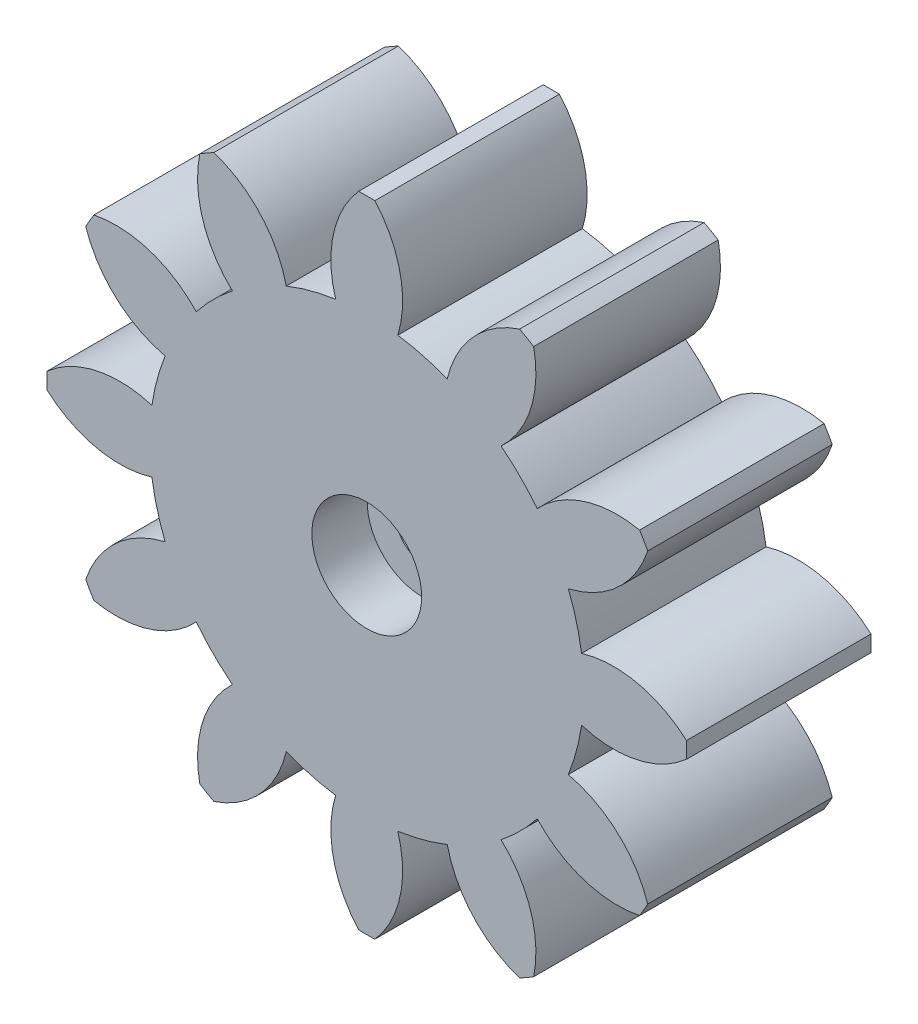
from build123d import *

# Parameters (mm, degrees)
BOSS_EXTRUDE1_DEPTH = 10
SKETCH3_R           = 2.975
CUT_EXTRUDE1_DEPTH  = 3
SKETCH4_R           = 2.975
CUT_EXTRUDE2_DEPTH  = 5
CUT_EXTRUDE3_REACH  = 7
SKETCH5_R           = 1.375
CUT_EXTRUDE4_DEPTH  = 0.4


with BuildPart() as part:
    # Sketch1 → Boss-Extrude1 (new body)
    with BuildSketch(Plane.XY):
        with BuildLine():
            ThreePointArc((10.92443124, -4.361437941), (11.362069294, -3.044457292), (11.641553947, -1.685099566))
            ThreePointArc((11.641553947, -1.685099566), (14.648632583, -1.806960077), (17.329910897, -0.440168758))
            ThreePointArc((17.329910897, -0.440168758), (17.3355, 0), (17.329910897, 0.440168758))
            ThreePointArc((17.329910897, 0.440168758), (14.648632583, 1.806960077), (11.641553947, 1.685099566))
            ThreePointArc((11.641553947, 1.685099566), (11.362069294, 3.044457292), (10.92443124, 4.361437941))
            ThreePointArc((10.92443124, 4.361437941), (13.589567986, 5.759442961), (15.228227462, 8.283758122))
            ThreePointArc((15.228227462, 8.283758122), (15.012983387, 8.66775), (14.788058703, 9.046152775))
            ThreePointArc((14.788058703, 9.046152775), (11.782607909, 8.889189622), (9.239331674, 7.280116005))
            ThreePointArc((9.239331674, 7.280116005), (8.317612002, 8.317612002), (7.280116005, 9.239331674))
            ThreePointArc((7.280116005, 9.239331674), (8.889189622, 11.782607909), (9.046152775, 14.788058703))
            ThreePointArc((9.046152775, 14.788058703), (8.66775, 15.012983387), (8.283758122, 15.228227462))
            ThreePointArc((8.283758122, 15.228227462), (5.759442961, 13.589567986), (4.361437941, 10.92443124))
            ThreePointArc((4.361437941, 10.92443124), (3.044457292, 11.362069294), (1.685099566, 11.641553947))
            ThreePointArc((1.685099566, 11.641553947), (1.806960077, 14.648632583), (0.440168758, 17.329910897))
            ThreePointArc((0.440168758, 17.329910897), (0, 17.3355), (-0.440168758, 17.329910897))
            ThreePointArc((-0.440168758, 17.329910897), (-1.806960077, 14.648632583), (-1.685099566, 11.641553947))
            ThreePointArc((-1.685099566, 11.641553947), (-3.044457292, 11.362069294), (-4.361437941, 10.92443124))
            ThreePointArc((-4.361437941, 10.92443124), (-5.759442961, 13.589567986), (-8.283758122, 15.228227462))
            ThreePointArc((-8.283758122, 15.228227462), (-8.66775, 15.012983387), (-9.046152775, 14.788058703))
            ThreePointArc((-9.046152775, 14.788058703), (-8.889189622, 11.782607909), (-7.280116005, 9.239331674))
            ThreePointArc((-7.280116005, 9.239331674), (-8.317612002, 8.317612002), (-9.239331674, 7.280116005))
            ThreePointArc((-9.239331674, 7.280116005), (-11.782607909, 8.889189622), (-14.788058703, 9.046152775))
            ThreePointArc((-14.788058703, 9.046152775), (-15.012983387, 8.66775), (-15.228227462, 8.283758122))
            ThreePointArc((-15.228227462, 8.283758122), (-13.589567986, 5.759442961), (-10.92443124, 4.361437941))
            ThreePointArc((-10.92443124, 4.361437941), (-11.362069294, 3.044457292), (-11.641553947, 1.685099566))
            ThreePointArc((-11.641553947, 1.685099566), (-14.648632583, 1.806960077), (-17.329910897, 0.440168758))
            ThreePointArc((-17.329910897, 0.440168758), (-17.3355, 0), (-17.329910897, -0.440168758))
            ThreePointArc((-17.329910897, -0.440168758), (-14.648632583, -1.806960077), (-11.641553947, -1.685099566))
            ThreePointArc((-11.641553947, -1.685099566), (-11.362069294, -3.044457292), (-10.92443124, -4.361437941))
            ThreePointArc((-10.92443124, -4.361437941), (-13.589567986, -5.759442961), (-15.228227462, -8.283758122))
            ThreePointArc((-15.228227462, -8.283758122), (-15.012983387, -8.66775), (-14.788058703, -9.046152775))
            ThreePointArc((-14.788058703, -9.046152775), (-11.782607909, -8.889189622), (-9.239331674, -7.280116005))
            ThreePointArc((-9.239331674, -7.280116005), (-8.317612002, -8.317612002), (-7.280116005, -9.239331674))
            ThreePointArc((-7.280116005, -9.239331674), (-8.889189622, -11.782607909), (-9.046152775, -14.788058703))
            ThreePointArc((-9.046152775, -14.788058703), (-8.66775, -15.012983387), (-8.283758122, -15.228227462))
            ThreePointArc((-8.283758122, -15.228227462), (-5.759442961, -13.589567986), (-4.361437941, -10.92443124))
            ThreePointArc((-4.361437941, -10.92443124), (-3.044457292, -11.362069294), (-1.685099566, -11.641553947))
            ThreePointArc((-1.685099566, -11.641553947), (-1.806960077, -14.648632583), (-0.440168758, -17.329910897))
            ThreePointArc((-0.440168758, -17.329910897), (0, -17.3355), (0.440168758, -17.329910897))
            ThreePointArc((0.440168758, -17.329910897), (1.806960077, -14.648632583), (1.685099566, -11.641553947))
            ThreePointArc((1.685099566, -11.641553947), (3.044457292, -11.362069294), (4.361437941, -10.92443124))
            ThreePointArc((4.361437941, -10.92443124), (5.759442961, -13.589567986), (8.283758122, -15.228227462))
            ThreePointArc((8.283758122, -15.228227462), (8.66775, -15.012983387), (9.046152775, -14.788058703))
            ThreePointArc((9.046152775, -14.788058703), (8.889189622, -11.782607909), (7.280116005, -9.239331674))
            ThreePointArc((7.280116005, -9.239331674), (8.317612002, -8.317612002), (9.239331674, -7.280116005))
            ThreePointArc((9.239331674, -7.280116005), (11.782607909, -8.889189622), (14.788058703, -9.046152775))
            ThreePointArc((14.788058703, -9.046152775), (15.012983387, -8.66775), (15.228227462, -8.283758122))
            ThreePointArc((15.228227462, -8.283758122), (13.589567986, -5.759442961), (10.92443124, -4.361437941))
        make_face()
    extrude(amount=BOSS_EXTRUDE1_DEPTH)

    # Sketch3 → Cut-Extrude1 (cut)
    with BuildSketch(Plane.XY.offset(10)):
        Circle(SKETCH3_R)
    extrude(amount=-CUT_EXTRUDE1_DEPTH, mode=Mode.SUBTRACT)

    # Sketch4 → Cut-Extrude2 (cut)
    with BuildSketch(Plane(origin=(0, 0, 0), x_dir=(-1, 0, 0), z_dir=(0, 0, -1))):
        Circle(SKETCH4_R)
    extrude(amount=-CUT_EXTRUDE2_DEPTH, mode=Mode.SUBTRACT)

    # Sketch5 → Cut-Extrude3 (cut, up to next)
    with BuildSketch(Plane(origin=(0, 0, 5), x_dir=(-1, 0, 0), z_dir=(0, 0, -1)), mode=Mode.PRIVATE) as cut_extrude3_sk1:
        Circle(SKETCH5_R)
    cut_extrude3_tool1 = extrude(cut_extrude3_sk1.sketch, amount=-CUT_EXTRUDE3_REACH, mode=Mode.PRIVATE) & part.part
    add(cut_extrude3_tool1.solids().sort_by_distance((0, 0, 5))[0], mode=Mode.SUBTRACT)

    # Sketch6 → Cut-Extrude4 (cut)
    with BuildSketch(Plane(origin=(0, 0, 0), x_dir=(-1, 0, 0), z_dir=(0, 0, -1))):
        Polygon((-2.618216479, 7.598722954), (-1.369925881, 7.598722954), (-1.397062633, 7.408765689), (-1.914356971, 7.408765689), (-2.18275641, 5.482056288), (-2.37398571, 5.482056288), (-2.105586271, 7.408765689), (-2.645353231, 7.408765689), align=None)
        with BuildLine():
            add(Edge.make_bspline(
                [(-0.466780849, 7.055987912), (-0.450230711, 7.05582637), (-0.417344464, 7.055505377), (-0.368540996, 7.050389965), (-0.320631892, 7.043455272), (-0.273890681, 7.033209653), (-0.228274333, 7.020039405), (-0.183797047, 7.003718771), (-0.139886963, 6.985373988), (-0.097861943, 6.963061744), (-0.056959643, 6.93914658), (-0.018469172, 6.912248414), (0.018217553, 6.883553528), (0.05209848, 6.852068656), (0.083565028, 6.818384713), (0.113001423, 6.782640371), (0.140098105, 6.744546559), (0.164595462, 6.704227452), (0.186767697, 6.662267959), (0.205810076, 6.618582201), (0.221812473, 6.573454595), (0.235635063, 6.527284032), (0.245748638, 6.479469202), (0.252716265, 6.430299353), (0.25780439, 6.379794636), (0.25811986, 6.345639936), (0.258279247, 6.328383745)],
                knots=[0, 0, 0, 0, 4.9626e-05, 9.861e-05, 0.000147062, 0.000194801, 0.000242036, 0.000289383, 0.000336874, 0.000384665, 0.000432005, 0.000478934, 0.000525421, 0.000571629, 0.000617526, 0.000663618, 0.000710444, 0.000757639, 0.000805055, 0.000852714, 0.00090046, 0.000948628, 0.000997195, 0.001046906, 0.001097579, 0.001149324, 0.001149324, 0.001149324, 0.001149324], degree=3))
            add(Edge.make_bspline(
                [(0.258279247, 6.328383745), (0.258039783, 6.308578593), (0.257564863, 6.269299702), (0.25111703, 6.210994824), (0.242013556, 6.153590639), (0.228820877, 6.097203636), (0.211893663, 6.041919503), (0.190810327, 5.98797899), (0.166897365, 5.934727262), (0.138391513, 5.883395436), (0.107072302, 5.833870752), (0.073382761, 5.786755537), (0.036549617, 5.742935538), (-0.002372315, 5.701702817), (-0.04403848, 5.66345401), (-0.088426282, 5.628104243), (-0.135229578, 5.595522836), (-0.184676123, 5.566327033), (-0.235762168, 5.539867628), (-0.289219479, 5.517520108), (-0.344037548, 5.497877287), (-0.400776526, 5.482306102), (-0.458924002, 5.469780542), (-0.519048579, 5.461676665), (-0.580721407, 5.455726724), (-0.622519609, 5.455190096), (-0.643593749, 5.454919536)],
                knots=[0, 0, 0, 0, 5.9386e-05, 0.000117778, 0.000175775, 0.00023368, 0.000291352, 0.00034907, 0.000407322, 0.000466339, 0.000525038, 0.000583054, 0.000639949, 0.000696635, 0.000753052, 0.000809471, 0.000866752, 0.000923981, 0.00098163, 0.001039198, 0.001097669, 0.001156204, 0.001215581, 0.001275965, 0.001338116, 0.001401316, 0.001401316, 0.001401316, 0.001401316], degree=3))
            add(Edge.make_bspline(
                [(-0.643593749, 5.454919536), (-0.669493428, 5.455383045), (-0.720215087, 5.456290778), (-0.79439634, 5.466548474), (-0.865066012, 5.482132761), (-0.932596844, 5.503609688), (-0.996247222, 5.532258194), (-1.056572504, 5.566773789), (-1.113195168, 5.607790827), (-1.165981922, 5.654584393), (-1.213474215, 5.70648827), (-1.255599117, 5.761915733), (-1.290839566, 5.821150442), (-1.31984552, 5.88380972), (-1.342346636, 5.949908511), (-1.358542659, 6.019333173), (-1.367836177, 6.092239873), (-1.369220429, 6.141933883), (-1.369925881, 6.167259279)],
                knots=[0, 0, 0, 0, 7.7651e-05, 0.000152071, 0.000224184, 0.000294581, 0.000364239, 0.000433188, 0.000502737, 0.00057362, 0.000644441, 0.00071347, 0.000782116, 0.000850791, 0.000920249, 0.000991216, 0.00106432, 0.001140294, 0.001140294, 0.001140294, 0.001140294], degree=3))
            add(Edge.make_bspline(
                [(-1.369925881, 6.167259279), (-1.369686634, 6.187346849), (-1.369212104, 6.227189251), (-1.362759891, 6.286341002), (-1.353696191, 6.344455032), (-1.340515163, 6.40142391), (-1.323365754, 6.45698532), (-1.303239948, 6.51160935), (-1.278207847, 6.564567741), (-1.250581409, 6.616609619), (-1.219162465, 6.666555184), (-1.184856791, 6.713974777), (-1.147928001, 6.75876754), (-1.107808488, 6.800408128), (-1.065080124, 6.839424555), (-1.019448587, 6.875464179), (-0.9715212, 6.909223719), (-0.920623878, 6.939512396), (-0.868016329, 6.966960034), (-0.813961342, 6.990907617), (-0.758740152, 7.010651127), (-0.702629226, 7.02747186), (-0.645186655, 7.040029408), (-0.586743519, 7.049425439), (-0.527104511, 7.055120684), (-0.487004359, 7.055697173), (-0.466780849, 7.055987912)],
                knots=[0, 0, 0, 0, 6.0234e-05, 0.000119469, 0.000178303, 0.000236621, 0.000294699, 0.000352663, 0.000411092, 0.000470279, 0.000529337, 0.000587944, 0.000645762, 0.000703341, 0.000761269, 0.000819212, 0.000877673, 0.00093701, 0.000996749, 0.001055602, 0.001114215, 0.001172576, 0.001231214, 0.001290467, 0.001350084, 0.001410741, 0.001410741, 0.001410741, 0.001410741], degree=3))
        make_face()
        with BuildLine():
            add(Edge.make_bspline(
                [(-0.472293002, 6.866030647), (-0.503747094, 6.865022695), (-0.566133209, 6.863023522), (-0.658065178, 6.845395471), (-0.74697014, 6.81671419), (-0.8179001, 6.783908088), (-0.872314578, 6.752977498), (-0.910614571, 6.727193913), (-0.946742967, 6.69944908), (-0.979981554, 6.669196258), (-1.011627398, 6.637641618), (-1.040171419, 6.603265542), (-1.066329268, 6.566962809), (-1.097983096, 6.516104928), (-1.130880322, 6.448766532), (-1.159486048, 6.363291926), (-1.176996833, 6.273551961), (-1.178969506, 6.212282932), (-1.179968616, 6.181251667)],
                knots=[0, 0, 0, 0, 9.4292e-05, 0.000187019, 0.000279676, 0.000373968, 0.00042088, 0.000467332, 0.000512367, 0.000557404, 0.000602079, 0.000646324, 0.000691278, 0.000736223, 0.000825918, 0.000915352, 0.001005996, 0.001099018, 0.001099018, 0.001099018, 0.001099018], degree=3))
            add(Edge.make_bspline(
                [(-1.179968616, 6.181251667), (-1.1794568, 6.161867569), (-1.178451954, 6.123810792), (-1.171245103, 6.068109016), (-1.158915609, 6.015297828), (-1.141843388, 5.965306456), (-1.120166741, 5.91788484), (-1.093381959, 5.873158688), (-1.061329114, 5.831519246), (-1.024961279, 5.793010338), (-0.984651842, 5.758346576), (-0.941503542, 5.727691836), (-0.895161957, 5.701906395), (-0.845807108, 5.681429065), (-0.794011633, 5.664525813), (-0.73908174, 5.653428903), (-0.681546468, 5.645797717), (-0.642065378, 5.645187438), (-0.62196915, 5.644876801)],
                knots=[0, 0, 0, 0, 5.8145e-05, 0.000114157, 0.000168153, 0.000220581, 0.000272377, 0.000324297, 0.000376622, 0.000429712, 0.000482923, 0.000535862, 0.000588248, 0.000641641, 0.000695949, 0.000751417, 0.000809532, 0.000869779, 0.000869779, 0.000869779, 0.000869779], degree=3))
            add(Edge.make_bspline(
                [(-0.62196915, 5.644876801), (-0.590524141, 5.645933886), (-0.528763332, 5.648010096), (-0.438477158, 5.664456418), (-0.352929935, 5.691901598), (-0.272103007, 5.729454032), (-0.197778454, 5.777916968), (-0.130845563, 5.836279067), (-0.071984641, 5.904158073), (-0.022332757, 5.980832092), (0.017761416, 6.063614509), (0.047409032, 6.150361963), (0.064739616, 6.24049149), (0.067121094, 6.301457184), (0.068321982, 6.332199851)],
                knots=[0, 0, 0, 0, 9.4292e-05, 0.000185198, 0.000274236, 0.000363199, 0.000451756, 0.000539509, 0.000628779, 0.000720394, 0.000812747, 0.00090406, 0.000994703, 0.001086905, 0.001086905, 0.001086905, 0.001086905], degree=3))
            add(Edge.make_bspline(
                [(0.068321982, 6.332199851), (0.067596039, 6.357703768), (0.066178212, 6.407515064), (0.052490613, 6.479882494), (0.031000633, 6.547823061), (0.000738925, 6.610911353), (-0.037430539, 6.668381502), (-0.083276432, 6.719204496), (-0.136040802, 6.763624821), (-0.195880428, 6.799826465), (-0.259971579, 6.829850478), (-0.328268896, 6.850426904), (-0.399271241, 6.863689881), (-0.447781945, 6.865244927), (-0.472293002, 6.866030647)],
                knots=[0, 0, 0, 0, 7.644e-05, 0.000149293, 0.000220094, 0.000289696, 0.000358492, 0.000426347, 0.000494371, 0.000564622, 0.000635577, 0.000706124, 0.000778068, 0.000851544, 0.000851544, 0.000851544, 0.000851544], degree=3))
        make_face(mode=Mode.SUBTRACT)
        with BuildLine():
            Line((0.776421608, 7.02885116), (0.967650909, 7.02885116))
            Line((0.967650909, 7.02885116), (0.932457933, 6.781228296))
            add(Edge.make_bspline(
                [(0.932457933, 6.781228296), (0.95525764, 6.803138201), (1.000002938, 6.846137227), (1.072430641, 6.902257527), (1.147347384, 6.949518214), (1.224612839, 6.988624493), (1.304555777, 7.018705794), (1.386761654, 7.040508587), (1.471519696, 7.05361281), (1.528855179, 7.05518975), (1.557875268, 7.055987912)],
                knots=[0, 0, 0, 0, 9.4812e-05, 0.000186072, 0.0002743, 0.0003602, 0.000445409, 0.000530053, 0.000614965, 0.000701991, 0.000701991, 0.000701991, 0.000701991], degree=3))
            add(Edge.make_bspline(
                [(1.557875268, 7.055987912), (1.584192867, 7.055471337), (1.635869811, 7.054456997), (1.711516019, 7.044905152), (1.783549539, 7.029392819), (1.851757058, 7.00707545), (1.916555994, 6.979203097), (1.97753369, 6.944637972), (2.03469906, 6.903571981), (2.087708757, 6.856739674), (2.136102849, 6.805245178), (2.178144461, 6.749427894), (2.214259749, 6.690243954), (2.242868415, 6.626972477), (2.266096403, 6.56066932), (2.282154079, 6.490571495), (2.29146759, 6.416830902), (2.292836344, 6.366430373), (2.293535658, 6.340680086)],
                knots=[0, 0, 0, 0, 7.8922e-05, 0.00015497, 0.000228326, 0.000299661, 0.000369924, 0.000439609, 0.000509503, 0.000580703, 0.000651501, 0.000721124, 0.000789988, 0.000859049, 0.000929045, 0.001000425, 0.00107437, 0.001151615, 0.001151615, 0.001151615, 0.001151615], degree=3))
            add(Edge.make_bspline(
                [(2.293535658, 6.340680086), (2.292756814, 6.310809362), (2.291221368, 6.2519209), (2.277974073, 6.16544013), (2.257296292, 6.082130479), (2.227913966, 6.001855526), (2.189452999, 5.925007168), (2.142976411, 5.851323822), (2.088249202, 5.780811596), (2.025651473, 5.714800282), (1.957599549, 5.654160368), (1.885694396, 5.600858306), (1.810960661, 5.555646543), (1.732910767, 5.518855238), (1.65201047, 5.489939258), (1.567893547, 5.469515219), (1.480912029, 5.457505724), (1.421945993, 5.455788903), (1.392086673, 5.454919536)],
                knots=[0, 0, 0, 0, 8.9567e-05, 0.000176576, 0.000261829, 0.000346742, 0.000432453, 0.000519152, 0.000607698, 0.000699783, 0.000791687, 0.000880816, 0.000967931, 0.001053283, 0.001139249, 0.001225223, 0.001312532, 0.001402099, 0.001402099, 0.001402099, 0.001402099], degree=3))
            add(Edge.make_bspline(
                [(1.392086673, 5.454919536), (1.36008557, 5.455877278), (1.297702186, 5.457744315), (1.207264878, 5.472815489), (1.122821871, 5.497537928), (1.043999269, 5.531754612), (0.971349306, 5.577623514), (0.904405343, 5.634036542), (0.843202, 5.701632583), (0.80859248, 5.752958596), (0.790838008, 5.779288526)],
                knots=[0, 0, 0, 0, 9.5962e-05, 0.000187069, 0.000274144, 0.000359388, 0.000443974, 0.000530946, 0.000621305, 0.000716485, 0.000716485, 0.000716485, 0.000716485], degree=3))
            Line((0.790838008, 5.779288526), (0.6678746, 4.912184493))
            Line((0.6678746, 4.912184493), (0.4766453, 4.912184493))
            Line((0.4766453, 4.912184493), (0.776421608, 7.02885116))
        make_face()
        with BuildLine():
            add(Edge.make_bspline(
                [(1.548547009, 6.866030647), (1.516964336, 6.86495289), (1.454651685, 6.862826475), (1.363186083, 6.846486382), (1.276118948, 6.818599665), (1.207326109, 6.786791703), (1.155258156, 6.75620511), (1.117925825, 6.730978147), (1.083157103, 6.70275848), (1.050269418, 6.672479986), (1.01928348, 6.639844547), (0.99047575, 6.604727345), (0.964099599, 6.567007331), (0.931552528, 6.514374386), (0.897108756, 6.44482235), (0.867718491, 6.356677676), (0.849813634, 6.264798947), (0.847534749, 6.202249068), (0.846383548, 6.170651373)],
                knots=[0, 0, 0, 0, 9.4715e-05, 0.000186873, 0.000277656, 0.000368335, 0.000413568, 0.000458728, 0.00050336, 0.000547771, 0.00059276, 0.000638256, 0.000683899, 0.000730733, 0.00082384, 0.000915956, 0.001008761, 0.001103502, 0.001103502, 0.001103502, 0.001103502], degree=3))
            add(Edge.make_bspline(
                [(0.846383548, 6.170651373), (0.846880401, 6.151687835), (0.84785555, 6.1144691), (0.855281967, 6.059969025), (0.866935692, 6.008041586), (0.883890562, 5.958899419), (0.90645881, 5.912918133), (0.93249753, 5.868896771), (0.964183934, 5.827973452), (1.000712796, 5.790469527), (1.040674711, 5.756302458), (1.083765653, 5.726286707), (1.129952142, 5.701296184), (1.178658217, 5.680303519), (1.230520431, 5.664740354), (1.284990487, 5.653397445), (1.342265236, 5.645810225), (1.3814616, 5.645191678), (1.401414931, 5.644876801)],
                knots=[0, 0, 0, 0, 5.6875e-05, 0.000111625, 0.000164699, 0.000216326, 0.000267151, 0.000318126, 0.00036952, 0.000421997, 0.000474932, 0.000527037, 0.000579218, 0.000632221, 0.000685872, 0.00074134, 0.000799033, 0.000858857, 0.000858857, 0.000858857, 0.000858857], degree=3))
            add(Edge.make_bspline(
                [(1.401414931, 5.644876801), (1.425190397, 5.645401392), (1.472082588, 5.64643604), (1.540974967, 5.655997841), (1.607293902, 5.671745595), (1.67090799, 5.693830093), (1.732023507, 5.721998881), (1.790365132, 5.756406863), (1.845607091, 5.797691261), (1.898274519, 5.843733104), (1.9462516, 5.894713202), (1.988627243, 5.949036817), (2.023867858, 6.006842659), (2.053425248, 6.067025352), (2.075840269, 6.130254393), (2.092225689, 6.196099235), (2.101446629, 6.26494454), (2.102861119, 6.311821231), (2.103578393, 6.335591945)],
                knots=[0, 0, 0, 0, 7.1296e-05, 0.000140616, 0.000208185, 0.0002755, 0.00034228, 0.000409763, 0.000478285, 0.000548887, 0.000619376, 0.000687989, 0.000755183, 0.000822125, 0.000888781, 0.000956038, 0.001025358, 0.001096673, 0.001096673, 0.001096673, 0.001096673], degree=3))
            add(Edge.make_bspline(
                [(2.103578393, 6.335591945), (2.103084075, 6.35497875), (2.102117155, 6.392900654), (2.094707841, 6.448394989), (2.082931157, 6.501085061), (2.066543011, 6.550976382), (2.044636177, 6.59774105), (2.017611356, 6.641345196), (1.986861031, 6.682940214), (1.950483335, 6.720388688), (1.910955275, 6.754734057), (1.867876985, 6.784605186), (1.821707243, 6.809606077), (1.772885678, 6.830695088), (1.720831223, 6.846087633), (1.666111937, 6.857566749), (1.608400351, 6.865104242), (1.568782329, 6.865717446), (1.548547009, 6.866030647)],
                knots=[0, 0, 0, 0, 5.8145e-05, 0.000113736, 0.000167637, 0.00021993, 0.000270956, 0.000322151, 0.000373626, 0.000425809, 0.000478422, 0.000530528, 0.000582709, 0.000635712, 0.000689768, 0.000745236, 0.00080335, 0.000864021, 0.000864021, 0.000864021, 0.000864021], degree=3))
        make_face(mode=Mode.SUBTRACT)
    extrude(amount=-CUT_EXTRUDE4_DEPTH, mode=Mode.SUBTRACT)


solid = part.part
